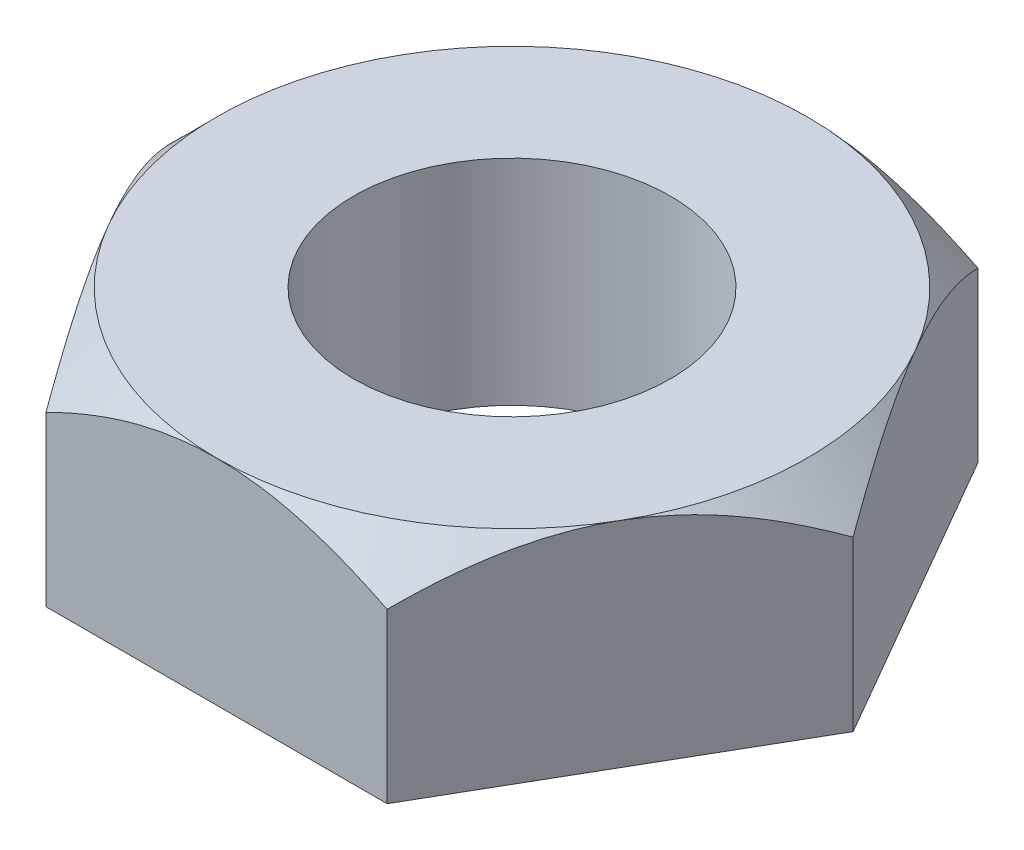
from build123d import *

# Parameters (mm, degrees)
BOSS_EXTRUDE1_DEPTH = 25
SKETCH2_OUTSIDE_W   = 153.338
SKETCH2_OUTSIDE_H   = 142.664
SKETCH2_OUTSIDE_R   = 34.5
CUT_EXTRUDE1_DEPTH  = 25
CUT_EXTRUDE1_TAPER  = 45
SKETCH3_R           = 18.5
CUT_EXTRUDE2_DEPTH  = 26


with BuildPart() as part:
    # Sketch1 → Boss-Extrude1 (new body)
    with BuildSketch(Plane(origin=(0, 0, 0), x_dir=(1, 0, 0), z_dir=(0, 1, 0))):
        Polygon((19.918584287, 34.5), (-19.918584287, 34.5), (-39.837168574, 0), (-19.918584287, -34.5), (19.918584287, -34.5), (39.837168574, 0), align=None)
    extrude(amount=BOSS_EXTRUDE1_DEPTH)

    # Sketch2 outside → Cut-Extrude1 (cut)
    with BuildSketch(Plane(origin=(0, 25, 0), x_dir=(1, 0, 0), z_dir=(0, 1, 0))):
        Rectangle(SKETCH2_OUTSIDE_W, SKETCH2_OUTSIDE_H)
        Circle(SKETCH2_OUTSIDE_R, mode=Mode.SUBTRACT)
    extrude(amount=-CUT_EXTRUDE1_DEPTH, taper=CUT_EXTRUDE1_TAPER, mode=Mode.SUBTRACT)

    # Sketch3 → Cut-Extrude2 (cut, through all)
    with BuildSketch(Plane(origin=(0, 25, 0), x_dir=(1, 0, 0), z_dir=(0, 1, 0))):
        Circle(SKETCH3_R)
    extrude(amount=-CUT_EXTRUDE2_DEPTH, mode=Mode.SUBTRACT)


solid = part.part
